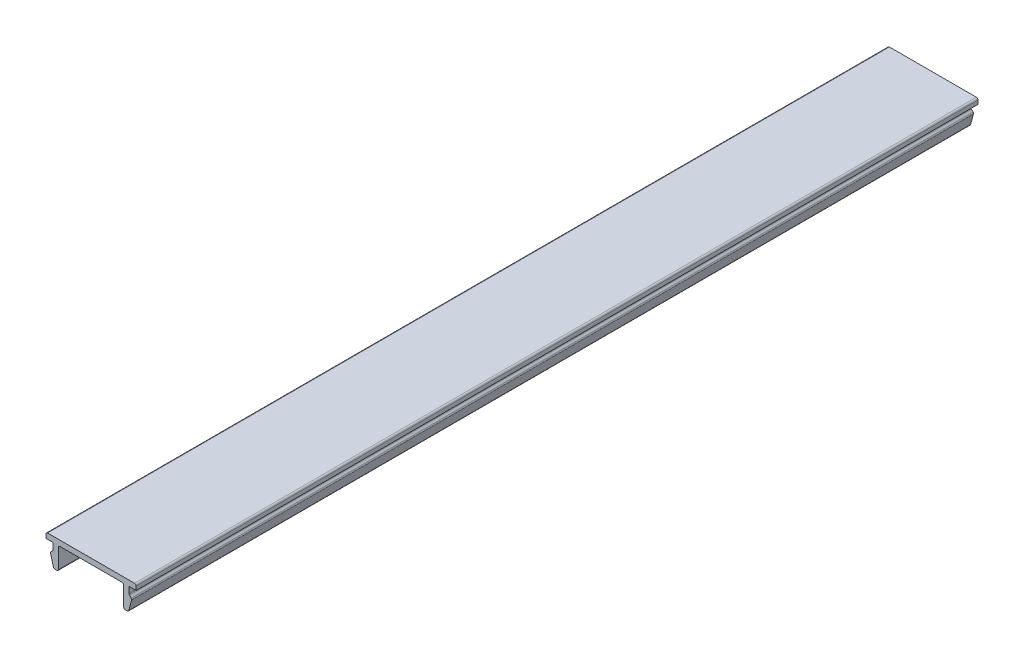
from build123d import *

# Parameters (mm, degrees)
BOSS_EXTRUDE1_DEPTH = 155
FILLET1_R           = 0.3


with BuildPart() as part:
    # Sketch1 → Boss-Extrude1 (new body)
    with BuildSketch(Plane.XY):
        Polygon((-8.3, 1), (8.3, 1), (8.3, 0), (7, 0), (7, -1.3), (7.5, -1.8), (6.883716857, -4.1), (6, -4.1), (6, 0), (-6, 0), (-6, -4.1), (-6.883716857, -4.1), (-7.5, -1.8), (-7, -1.3), (-7, 0), (-8.3, 0), align=None)
    extrude(amount=BOSS_EXTRUDE1_DEPTH)

    # Fillet1
    fillet1_edges = [part.edges().sort_by_distance(p)[0] for p in [
        (-8.3, 1, 77.5),
        (8.3, 1, 77.5),
        (7, -1.3, 77.5),
        (7.5, -1.8, 77.5),
        (6.883716857, -4.1, 77.5),
        (6, -4.1, 77.5),
        (6, 0, 77.5),
        (-6, 0, 77.5),
        (-6, -4.1, 77.5),
        (-6.883716857, -4.1, 77.5),
        (-7.5, -1.8, 77.5),
        (-7, -1.3, 77.5),
    ]]
    fillet(fillet1_edges, radius=FILLET1_R)


solid = part.part
